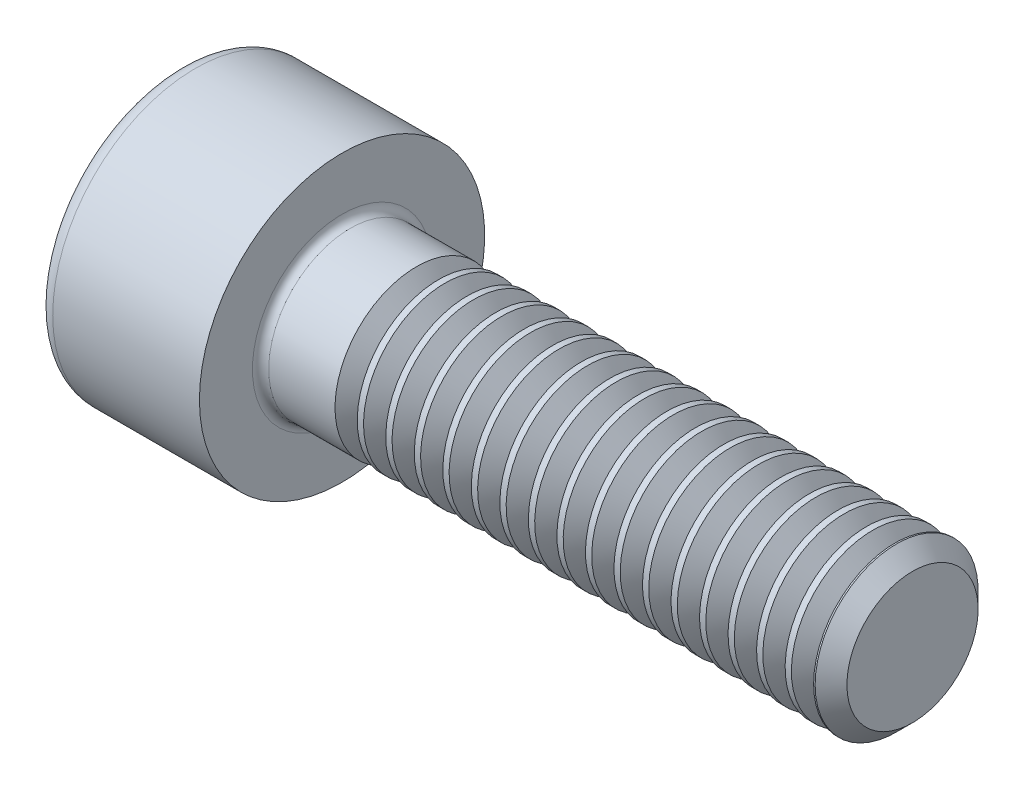
from build123d import *

# Parameters (mm, degrees)
FILLET1_R       = 0.2
FILLET2_R       = 0.4
HEX_2_DEPTH     = 2
THDSCHPAT_COUNT = 17
THDSCHPAT_PITCH = 0.7


with BuildPart() as part:
    # BodySke → Base-Revolve (revolve)
    with BuildSketch(Plane.XY, mode=Mode.PRIVATE) as base_revolve_sk:
        Polygon((0, 0), (0, 3.5), (4, 3.5), (4, 2), (17.61, 2), (18, 1.61), (18, 0), align=None)
    revolve(base_revolve_sk.sketch.rotate(Axis((-31.75, 0, 0), (1, 0, 0)), 90), axis=Axis((-31.75, 0, 0), (1, 0, 0)))  # turned: the seam where the file's is

    # Fillet1
    fillet1_edges = [part.edges().sort_by_distance(p)[0] for p in [
        (4, 0, -2),
    ]]
    fillet(fillet1_edges, radius=FILLET1_R)

    # Fillet2
    fillet2_edges = [part.edges().sort_by_distance(p)[0] for p in [
        (0, 0, -3.5),
    ]]
    fillet(fillet2_edges, radius=FILLET2_R)

    # Sketch2 → Hex-PreBroach (revolve, cut)
    with BuildSketch(Plane.XY, mode=Mode.PRIVATE) as hex_prebroach_sk:
        Polygon((0, 1.51), (2, 1.51), (2.871798906, 0), (0, 0), align=None)
    revolve(hex_prebroach_sk.sketch.rotate(Axis((0, 0, 0), (1, 0, 0)), 90), axis=Axis((0, 0, 0), (1, 0, 0)), mode=Mode.SUBTRACT)  # turned: the seam where the file's is

    # Sketch3 → Hex 2 (cut)
    with BuildSketch(Plane(origin=(0, 0, 0), x_dir=(0, 0.5, 0.866025404), z_dir=(-1, 0, 0))):
        Polygon((0.871798906, 1.51), (-0.871798906, 1.51), (-1.743597813, 0), (-0.871798906, -1.51), (0.871798906, -1.51), (1.743597813, 0), align=None)
    extrude(amount=-HEX_2_DEPTH, mode=Mode.SUBTRACT)

    # ThdSchSke → ThreadSchematic (revolve, cut)
    with BuildSketch(Plane.XY, mode=Mode.PRIVATE) as threadschematic_sk:
        Polygon((6.1, -1.61), (5.82691906, -2), (5.82691906, -2.5), (6.37308094, -2.5), (6.37308094, -2), align=None)
    threadschematic = revolve(threadschematic_sk.sketch.rotate(Axis((-3.175, 0, 0), (1, 0, 0)), 270), axis=Axis((-3.175, 0, 0), (1, 0, 0)), mode=Mode.SUBTRACT)  # turned: the seam where the file's is

    # ThdSchPat: ThreadSchematic ×17
    with Locations(*[(i * THDSCHPAT_PITCH, 0, 0) for i in range(1, THDSCHPAT_COUNT)]):
        add(threadschematic, mode=Mode.SUBTRACT)


solid = part.part
